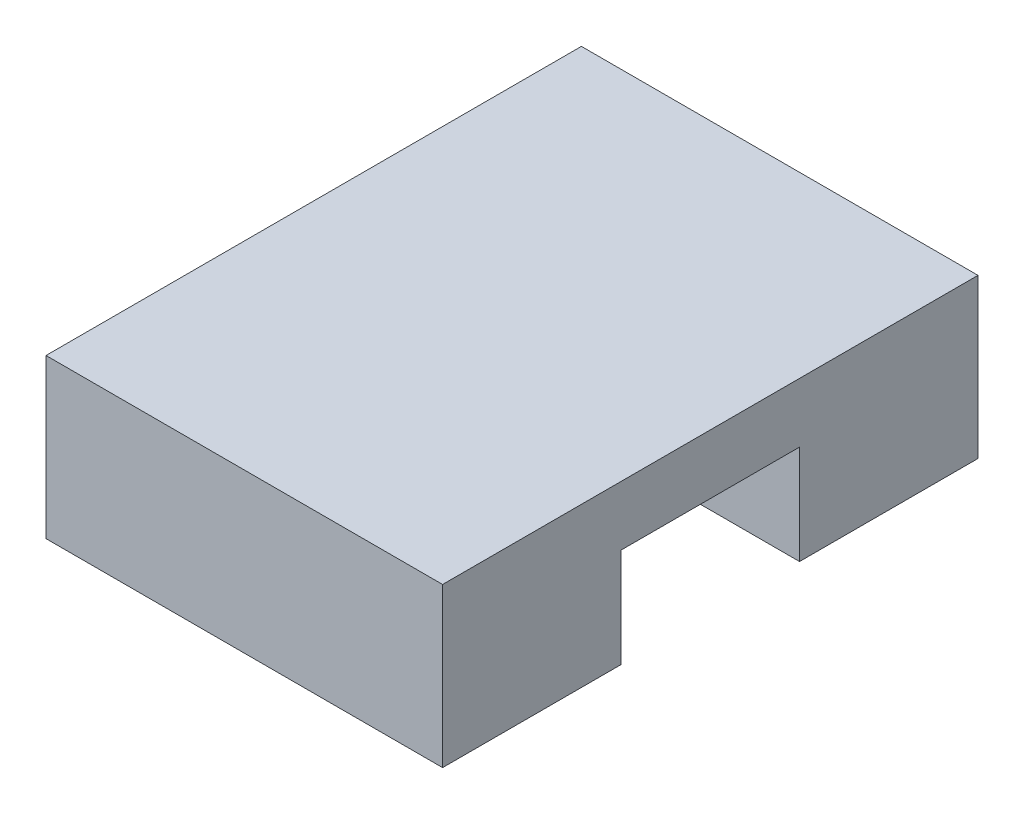
from build123d import *

# Parameters (mm, degrees)
SKETCH1_W           = 20
SKETCH1_H           = 27
BOSS_EXTRUDE1_DEPTH = 8
SKETCH2_W           = 9
SKETCH2_H           = 5
CUT_EXTRUDE1_DEPTH  = 20


with BuildPart() as part:
    # Sketch1 → Boss-Extrude1 (new body)
    with BuildSketch(Plane(origin=(0, 0, 0), x_dir=(1, 0, 0), z_dir=(0, 1, 0))):
        with Locations((-10.903225806, -3.629032258)):
            Rectangle(SKETCH1_W, SKETCH1_H)
    extrude(amount=BOSS_EXTRUDE1_DEPTH)

    # Sketch2 → Cut-Extrude1 (cut)
    with BuildSketch(Plane.ZY.offset(20.903225806)):
        with Locations((3.629032258, 2.5)):
            Rectangle(SKETCH2_W, SKETCH2_H)
    extrude(amount=-CUT_EXTRUDE1_DEPTH, mode=Mode.SUBTRACT)


solid = part.part
